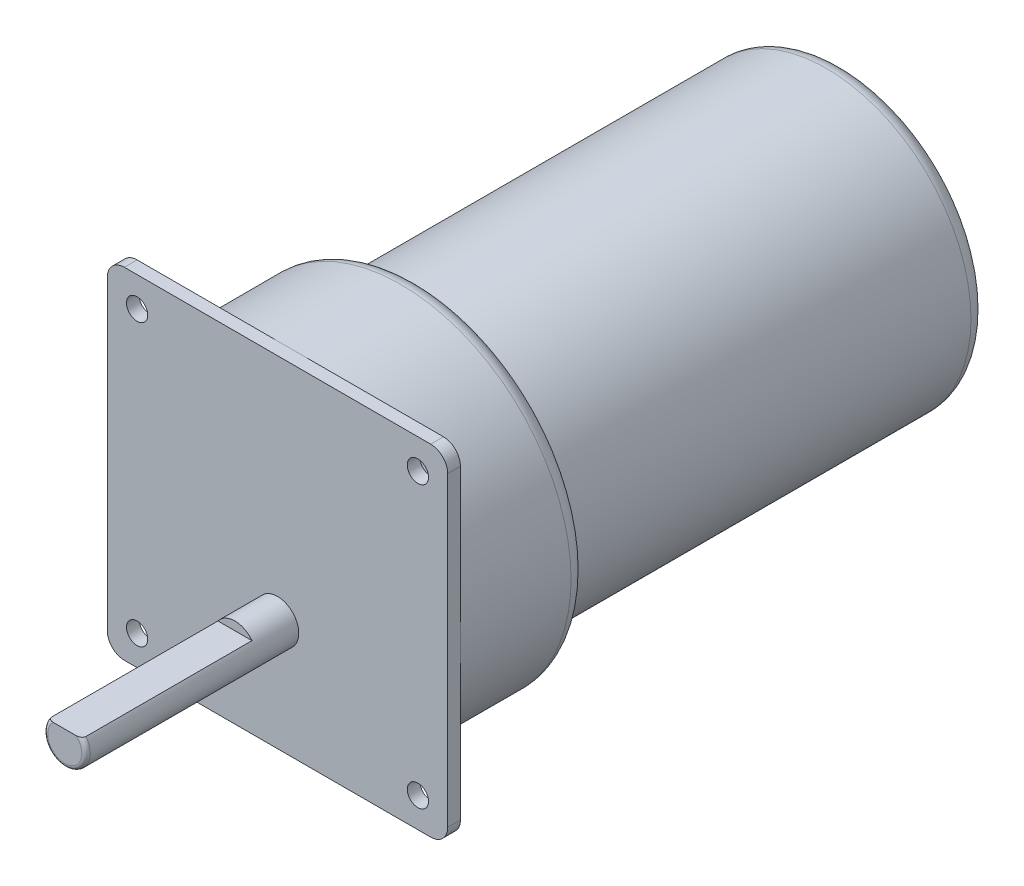
from build123d import *

# Parameters (mm, degrees)
SKETCH1_R           = 40
BOSS_EXTRUDE1_DEPTH = 30
SKETCH2_W           = 80
SKETCH2_H           = 80
SKETCH2_R           = 2.5
BOSS_EXTRUDE2_DEPTH = 3
FILLET1_R           = 4
SKETCH3_R           = 34
BOSS_EXTRUDE3_DEPTH = 100
FILLET2_R           = 4
SKETCH4_R           = 5
BOSS_EXTRUDE4_DEPTH = 50
FILLET3_R           = 1
SKETCH5_W           = 42.68943546
SKETCH5_H           = 2
CUT_EXTRUDE1_DEPTH  = 81


with BuildPart() as part:
    # Sketch1 → Boss-Extrude1 (new body)
    with BuildSketch(Plane.XY):
        Circle(SKETCH1_R)
    extrude(amount=BOSS_EXTRUDE1_DEPTH)

    # Sketch2 → Boss-Extrude2 (add)
    with BuildSketch(Plane.XY.offset(30)):
        Rectangle(SKETCH2_W, SKETCH2_H)
        with Locations((33, -33)):
            Circle(SKETCH2_R, mode=Mode.SUBTRACT)
        with Locations((-33, 33)):
            Circle(SKETCH2_R, mode=Mode.SUBTRACT)
        with Locations((33, 33)):
            Circle(SKETCH2_R, mode=Mode.SUBTRACT)
        with Locations((-33, -33)):
            Circle(SKETCH2_R, mode=Mode.SUBTRACT)
    extrude(amount=BOSS_EXTRUDE2_DEPTH)

    # Fillet1
    fillet1_edges = [part.edges().sort_by_distance(p)[0] for p in [
        (40, 40, 31.5),
        (-40, 40, 31.5),
        (-40, -40, 31.5),
        (40, -40, 31.5),
    ]]
    fillet(fillet1_edges, radius=FILLET1_R)

    # Sketch3 → Boss-Extrude3 (add)
    with BuildSketch(Plane(origin=(0, 0, 0), x_dir=(-1, 0, 0), z_dir=(0, 0, -1))):
        Circle(SKETCH3_R)
    extrude(amount=BOSS_EXTRUDE3_DEPTH)

    # Fillet2
    fillet2_edges = [part.edges().sort_by_distance(p)[0] for p in [
        (-40, 0, 0),
        (34, 0, -100),
    ]]
    fillet(fillet2_edges, radius=FILLET2_R)

    # Sketch4 → Boss-Extrude4 (add)
    with BuildSketch(Plane.XY.offset(33)):
        with Locations((0, -14)):
            Circle(SKETCH4_R)
    extrude(amount=BOSS_EXTRUDE4_DEPTH)

    # Fillet3
    fillet3_edges = [part.edges().sort_by_distance(p)[0] for p in [
        (-5, -14, 83),
    ]]
    fillet(fillet3_edges, radius=FILLET3_R)

    # Sketch5 → Cut-Extrude1 (cut, through all)
    with BuildSketch(Plane.ZY.offset(40)):
        with Locations((64.34471773, -10)):
            Rectangle(SKETCH5_W, SKETCH5_H)
    extrude(amount=-CUT_EXTRUDE1_DEPTH, mode=Mode.SUBTRACT)


solid = part.part
